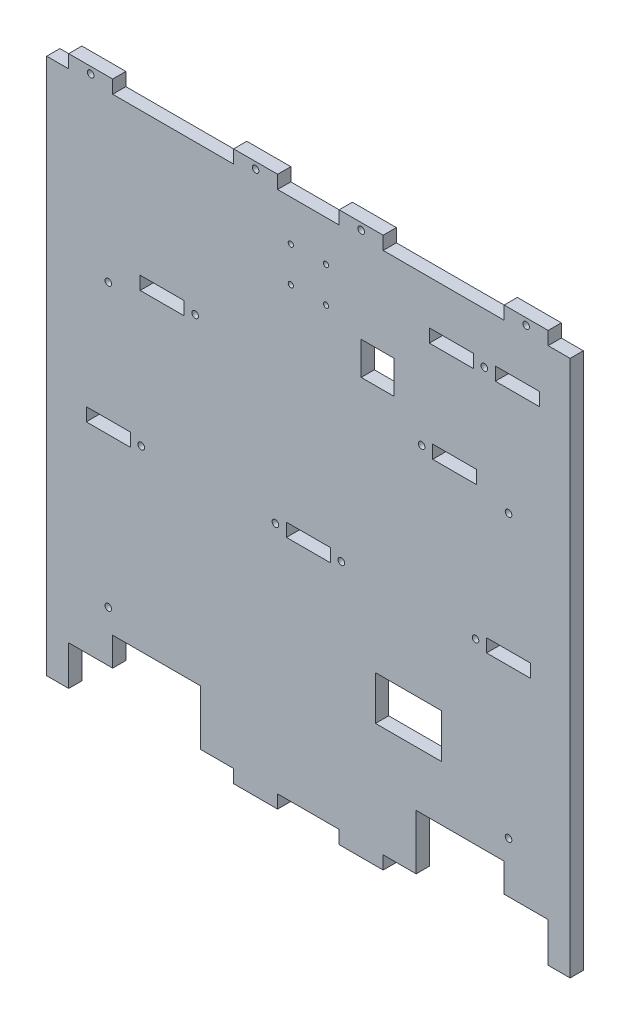
from build123d import *

# Parameters (mm, degrees)
ESQUISSE1_W             = 218
ESQUISSE1_H             = 238
ESQUISSE1_W_2           = 20
ESQUISSE1_H_2           = 6
ESQUISSE1_W_3           = 30
ESQUISSE1_H_3           = 20
ESQUISSE1_W_4           = 15
ESQUISSE1_H_4           = 15
BOSS_EXTRU_1_DEPTH      = 6
ESQUISSE2_W             = 40
ESQUISSE2_H             = 25
ENL_V_MAT_EXTRU_1_DEPTH = 6
ESQUISSE3_W             = 20
ESQUISSE3_H             = 6
BOSS_EXTRU_3_DEPTH      = 6
ESQUISSE4_R             = 1.5
ENL_V_MAT_EXTRU_2_DEPTH = 6
ESQUISSE5_W             = 10
ESQUISSE5_H             = 244
BOSS_EXTRU_4_DEPTH      = 6
ESQUISSE6_W             = 20
ESQUISSE6_H             = 12
ENL_V_MAT_EXTRU_3_DEPTH = 6
ESQUISSE7_R             = 1.175
ENL_V_MAT_EXTRU_4_DEPTH = 7


with BuildPart() as part:
    # Esquisse1 → Boss.-Extru.1 (new body)
    with BuildSketch(Plane.XY):
        Rectangle(ESQUISSE1_W, ESQUISSE1_H)
        with Locations((-91, -13)):
            Rectangle(ESQUISSE1_W_2, ESQUISSE1_H_2, mode=Mode.SUBTRACT)
        with Locations((0, -13)):
            Rectangle(ESQUISSE1_W_2, ESQUISSE1_H_2, mode=Mode.SUBTRACT)
        with Locations((91, -13)):
            Rectangle(ESQUISSE1_W_2, ESQUISSE1_H_2, mode=Mode.SUBTRACT)
        with Locations((-66.5, 51)):
            Rectangle(ESQUISSE1_W_2, ESQUISSE1_H_2, mode=Mode.SUBTRACT)
        with Locations((66.5, 51)):
            Rectangle(ESQUISSE1_W_2, ESQUISSE1_H_2, mode=Mode.SUBTRACT)
        with Locations((45.5, -59)):
            Rectangle(ESQUISSE1_W_3, ESQUISSE1_H_3, mode=Mode.SUBTRACT)
        with Locations((65, 96)):
            Rectangle(ESQUISSE1_W_2, ESQUISSE1_H_2, mode=Mode.SUBTRACT)
        with Locations((95, 96)):
            Rectangle(ESQUISSE1_W_2, ESQUISSE1_H_2, mode=Mode.SUBTRACT)
        with Locations((31.5, 71.5)):
            Rectangle(ESQUISSE1_W_4, ESQUISSE1_H_4, mode=Mode.SUBTRACT)
    extrude(amount=BOSS_EXTRU_1_DEPTH)

    # Esquisse2 → Enlèv. mat.-Extru.1 (cut)
    with BuildSketch(Plane.XY.offset(6)):
        with Locations((-69, -106.5)):
            Rectangle(ESQUISSE2_W, ESQUISSE2_H)
        with Locations((69, -106.5)):
            Rectangle(ESQUISSE2_W, ESQUISSE2_H)
    extrude(amount=-ENL_V_MAT_EXTRU_1_DEPTH, mode=Mode.SUBTRACT)

    # Esquisse3 → Boss.-Extru.3 (add)
    with BuildSketch(Plane.XY.offset(6)):
        with Locations((-24, -122)):
            Rectangle(ESQUISSE3_W, ESQUISSE3_H)
        with Locations((24, -122)):
            Rectangle(ESQUISSE3_W, ESQUISSE3_H)
        with Locations((24, 122)):
            Rectangle(ESQUISSE3_W, ESQUISSE3_H)
        with Locations((99, 122)):
            Rectangle(ESQUISSE3_W, ESQUISSE3_H)
        with Locations((-24, 122)):
            Rectangle(ESQUISSE3_W, ESQUISSE3_H)
        with Locations((-99, 122)):
            Rectangle(ESQUISSE3_W, ESQUISSE3_H)
    extrude(amount=-BOSS_EXTRU_3_DEPTH)

    # Esquisse4 → Enlèv. mat.-Extru.2 (cut)
    with BuildSketch(Plane.XY.offset(6)):
        with Locations((-15, -13)):
            Circle(ESQUISSE4_R)
        with Locations((-76, -13)):
            Circle(ESQUISSE4_R)
        with Locations((80, 96)):
            Circle(ESQUISSE4_R)
        with Locations((51.5, 51)):
            Circle(ESQUISSE4_R)
        with Locations((76, -13)):
            Circle(ESQUISSE4_R)
        with Locations((15, -13)):
            Circle(ESQUISSE4_R)
        with Locations((-51.5, 51)):
            Circle(ESQUISSE4_R)
        with Locations((-99, 122)):
            Circle(ESQUISSE4_R)
        with Locations((-24, 122)):
            Circle(ESQUISSE4_R)
        with Locations((24, 122)):
            Circle(ESQUISSE4_R)
        with Locations((99, 122)):
            Circle(ESQUISSE4_R)
        with Locations((-91, -84)):
            Circle(ESQUISSE4_R)
        with Locations((-91, 44)):
            Circle(ESQUISSE4_R)
        with Locations((91, -84)):
            Circle(ESQUISSE4_R)
        with Locations((91, 44)):
            Circle(ESQUISSE4_R)
    extrude(amount=-ENL_V_MAT_EXTRU_2_DEPTH, mode=Mode.SUBTRACT)

    # Esquisse5 → Boss.-Extru.4 (add)
    with BuildSketch(Plane.XY.offset(6)):
        with Locations((-114, -3)):
            Rectangle(ESQUISSE5_W, ESQUISSE5_H)
        with Locations((114, -3)):
            Rectangle(ESQUISSE5_W, ESQUISSE5_H)
    extrude(amount=-BOSS_EXTRU_4_DEPTH)

    # Esquisse6 → Enlèv. mat.-Extru.3 (cut)
    with BuildSketch(Plane.XY.offset(6)):
        with Locations((99, -113)):
            Rectangle(ESQUISSE6_W, ESQUISSE6_H)
        with Locations((-99, -113)):
            Rectangle(ESQUISSE6_W, ESQUISSE6_H)
    extrude(amount=-ENL_V_MAT_EXTRU_3_DEPTH, mode=Mode.SUBTRACT)

    # Esquisse7 → Enlèv. mat.-Extru.4 (cut, through all)
    with BuildSketch(Plane.XY.offset(6)):
        with Locations((-8, 100.5)):
            Circle(ESQUISSE7_R)
        with Locations((8, 100.5)):
            Circle(ESQUISSE7_R)
        with Locations((-8, 84.5)):
            Circle(ESQUISSE7_R)
        with Locations((8, 84.5)):
            Circle(ESQUISSE7_R)
    extrude(amount=-ENL_V_MAT_EXTRU_4_DEPTH, mode=Mode.SUBTRACT)


solid = part.part
